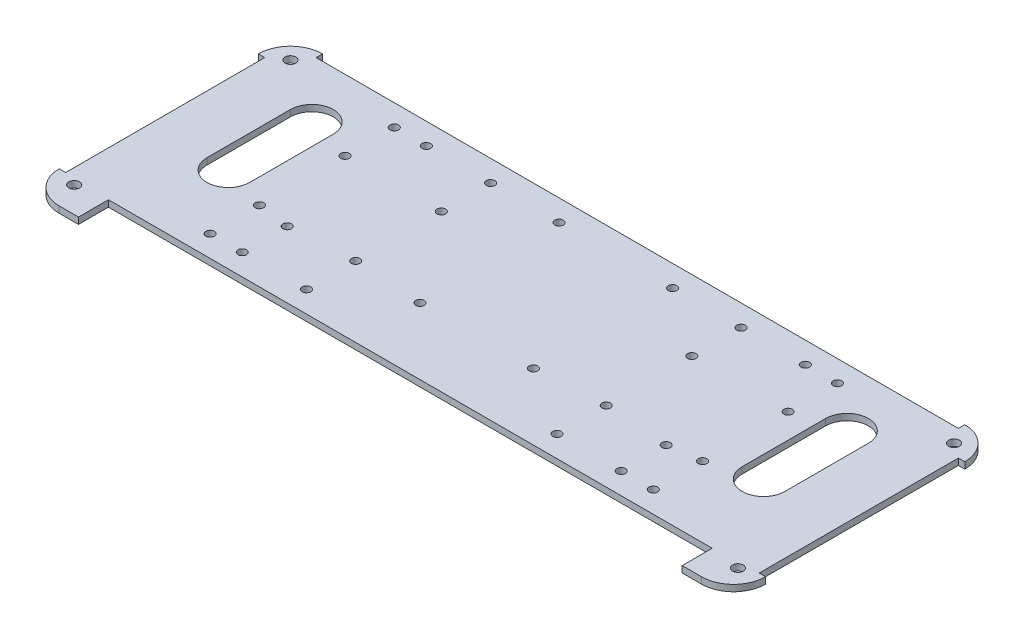
from build123d import *

# Parameters (mm, degrees)
ESQUISSE1_R      = 2.5
EXTRUSION1_DEPTH = 3
CONG_1_R         = 15
EXTRUSION2_REACH = 5
ESQUISSE2_W      = 300
ESQUISSE2_H      = 3
ESQUISSE2_W_2    = 3
ESQUISSE2_H_2    = 93
ESQUISSE3_R      = 2
EXTRUSION3_DEPTH = 3


with BuildPart() as part:
    # Esquisse1 → Extrusion1 (new body)
    with BuildSketch(Plane(origin=(0, 0, 0), x_dir=(1, 0, 0), z_dir=(0, 1, 0))):
        Polygon((0, 0), (24, 0), (24, 14), (306, 14), (306, 0), (330, 0), (330, 123), (0, 123), align=None)
        with Locations((10, 113)):
            Circle(ESQUISSE1_R, mode=Mode.SUBTRACT)
        with Locations((320, 113)):
            Circle(ESQUISSE1_R, mode=Mode.SUBTRACT)
        with Locations((10, 12)):
            Circle(ESQUISSE1_R, mode=Mode.SUBTRACT)
        with Locations((320, 12)):
            Circle(ESQUISSE1_R, mode=Mode.SUBTRACT)
        with BuildLine():
            Line((280, 93), (280, 54))
            ThreePointArc((280, 54), (290, 44), (300, 54))
            Line((300, 54), (300, 93))
            ThreePointArc((300, 93), (290, 103), (280, 93))
        make_face(mode=Mode.SUBTRACT)
        with BuildLine():
            Line((30, 93), (30, 54))
            ThreePointArc((30, 54), (40, 44), (50, 54))
            Line((50, 54), (50, 93))
            ThreePointArc((50, 93), (40, 103), (30, 93))
        make_face(mode=Mode.SUBTRACT)
    extrude(amount=EXTRUSION1_DEPTH)

    # Congé1
    cong_1_edges = [part.edges().sort_by_distance(p)[0] for p in [
        (0, 1.5, -123),
        (330, 1.5, -123),
        (330, 1.5, 0),
        (0, 1.5, 0),
    ]]
    fillet(cong_1_edges, radius=CONG_1_R)

    # Esquisse2 → Extrusion2 (cut, up to next)
    with BuildSketch(Plane(origin=(0, 3, 0), x_dir=(1, 0, 0), z_dir=(0, 1, 0)), mode=Mode.PRIVATE) as extrusion2_sk1:
        with Locations((165, 121.5)):
            Rectangle(ESQUISSE2_W, ESQUISSE2_H)
    extrusion2_tool1 = extrude(extrusion2_sk1.sketch, amount=-EXTRUSION2_REACH, mode=Mode.PRIVATE) & part.part
    add(extrusion2_tool1.solids().sort_by_distance((165, 3, -121.5))[0], mode=Mode.SUBTRACT)
    # Esquisse2 → Extrusion2 (cut, up to next)
    with BuildSketch(Plane(origin=(0, 3, 0), x_dir=(1, 0, 0), z_dir=(0, 1, 0)), mode=Mode.PRIVATE) as extrusion2_sk2:
        with Locations((1.5, 61.5)):
            Rectangle(ESQUISSE2_W_2, ESQUISSE2_H_2)
    extrusion2_tool2 = extrude(extrusion2_sk2.sketch, amount=-EXTRUSION2_REACH, mode=Mode.PRIVATE) & part.part
    add(extrusion2_tool2.solids().sort_by_distance((1.5, 3, -61.5))[0], mode=Mode.SUBTRACT)
    # Esquisse2 → Extrusion2 (cut, up to next)
    with BuildSketch(Plane(origin=(0, 3, 0), x_dir=(1, 0, 0), z_dir=(0, 1, 0)), mode=Mode.PRIVATE) as extrusion2_sk3:
        with Locations((328.5, 61.5)):
            Rectangle(ESQUISSE2_W_2, ESQUISSE2_H_2)
    extrusion2_tool3 = extrude(extrusion2_sk3.sketch, amount=-EXTRUSION2_REACH, mode=Mode.PRIVATE) & part.part
    add(extrusion2_tool3.solids().sort_by_distance((328.5, 3, -61.5))[0], mode=Mode.SUBTRACT)

    # Esquisse3 → Extrusion3 (cut)
    with BuildSketch(Plane(origin=(0, 3, 0), x_dir=(1, 0, 0), z_dir=(0, 1, 0))):
        with Locations((76.5, 110)):
            Circle(ESQUISSE3_R)
        with Locations((253.5, 110)):
            Circle(ESQUISSE3_R)
        with Locations((76.5, 24)):
            Circle(ESQUISSE3_R)
        with Locations((253.5, 24)):
            Circle(ESQUISSE3_R)
        with Locations((61.5, 110)):
            Circle(ESQUISSE3_R)
        with Locations((106.5, 110)):
            Circle(ESQUISSE3_R)
        with Locations((61.5, 87)):
            Circle(ESQUISSE3_R)
        with Locations((106.5, 87)):
            Circle(ESQUISSE3_R)
        with Locations((61.5, 47)):
            Circle(ESQUISSE3_R)
        with Locations((106.5, 47)):
            Circle(ESQUISSE3_R)
        with Locations((106.5, 24)):
            Circle(ESQUISSE3_R)
        with Locations((61.5, 24)):
            Circle(ESQUISSE3_R)
        with Locations((223.5, 87)):
            Circle(ESQUISSE3_R)
        with Locations((223.5, 110)):
            Circle(ESQUISSE3_R)
        with Locations((268.5, 110)):
            Circle(ESQUISSE3_R)
        with Locations((268.5, 87)):
            Circle(ESQUISSE3_R)
        with Locations((268.5, 47)):
            Circle(ESQUISSE3_R)
        with Locations((268.5, 24)):
            Circle(ESQUISSE3_R)
        with Locations((223.5, 24)):
            Circle(ESQUISSE3_R)
        with Locations((223.5, 47)):
            Circle(ESQUISSE3_R)
        with Locations((191.5, 110)):
            Circle(ESQUISSE3_R)
        with Locations((191.5, 45)):
            Circle(ESQUISSE3_R)
        with Locations((138.5, 45)):
            Circle(ESQUISSE3_R)
        with Locations((138.5, 110)):
            Circle(ESQUISSE3_R)
        with Locations((76.5, 45)):
            Circle(ESQUISSE3_R)
        with Locations((253.5, 45)):
            Circle(ESQUISSE3_R)
    extrude(amount=-EXTRUSION3_DEPTH, mode=Mode.SUBTRACT)


solid = part.part
